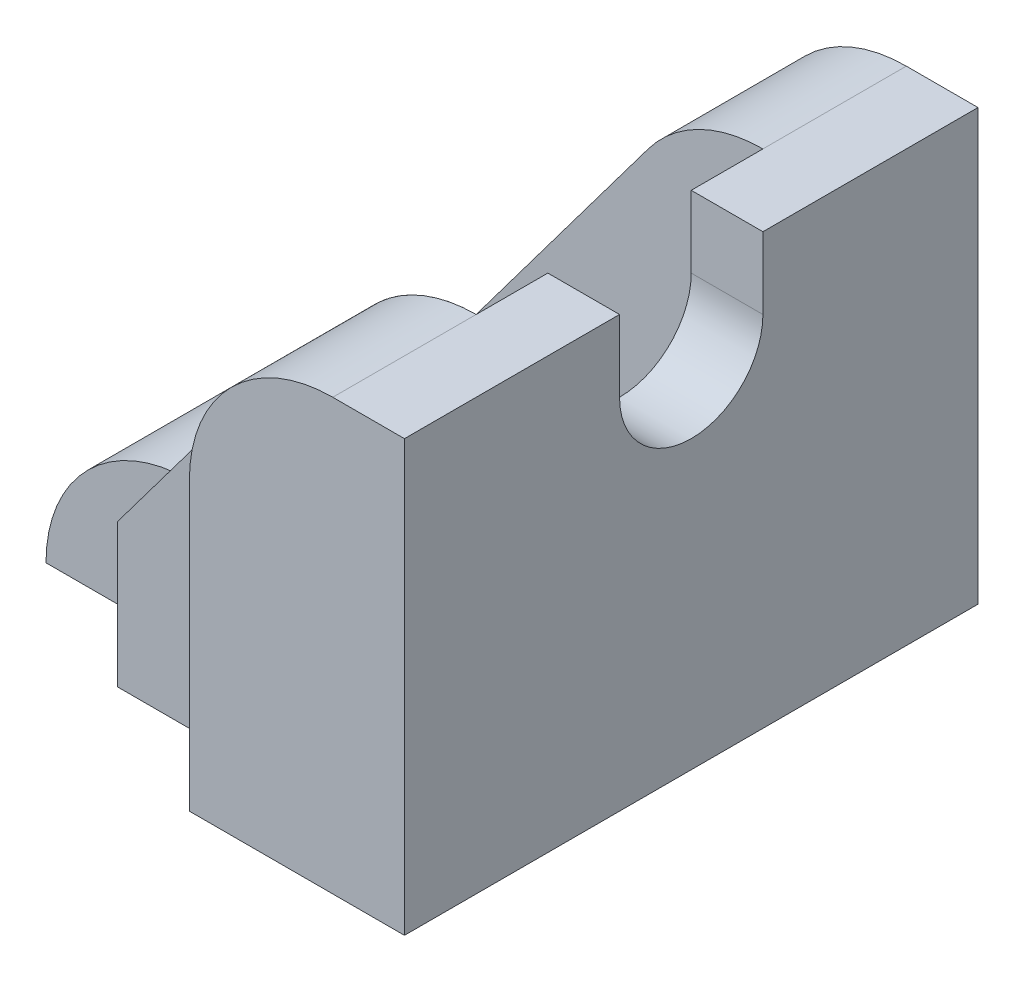
from build123d import *

# Parameters (mm, degrees)
BOSS_EXTRUDE1_DEPTH = 8
SKETCH2_W           = 4
SKETCH2_H           = 4
CUT_EXTRUDE1_DEPTH  = 4
CUT_EXTRUDE2_DEPTH  = 2
BOSS_EXTRUDE2_DEPTH = 6
CUT_EXTRUDE4_DEPTH  = 2
CUT_EXTRUDE5_DEPTH  = 3
CUT_EXTRUDE8_DEPTH  = 1
CUT_EXTRUDE9_DEPTH  = 1


with BuildPart() as part:
    # Sketch1 → Boss-Extrude1 (new body)
    with BuildSketch(Plane.XY):
        with BuildLine():
            Line((0, 0), (-3, 0))
            Line((-3, 0), (-5, 0))
            Line((-5, 0), (-5, 2))
            Line((-5, 2), (-2.6, 5.2))
            ThreePointArc((-2.6, 5.2), (-1.894427191, 5.788854382), (-1, 6))
            Line((-1, 6), (0, 6))
            Line((0, 6), (0, 0))
        make_face()
    extrude(amount=BOSS_EXTRUDE1_DEPTH)

    # Sketch2 → Cut-Extrude1 (cut)
    with BuildSketch(Plane(origin=(0, 6, 0), x_dir=(1, 0, 0), z_dir=(0, 1, 0))):
        with Locations((-3, -4)):
            Rectangle(SKETCH2_W, SKETCH2_H)
    extrude(amount=-CUT_EXTRUDE1_DEPTH, mode=Mode.SUBTRACT)

    # Sketch3 → Cut-Extrude2 (cut, through all)
    with BuildSketch(Plane.ZY.offset(1)):
        with BuildLine():
            Line((3, 6), (3, 5))
            ThreePointArc((3, 5), (4, 4), (5, 5))
            Line((5, 5), (5, 6))
            Line((5, 6), (3, 6))
        make_face()
    extrude(amount=-CUT_EXTRUDE2_DEPTH, mode=Mode.SUBTRACT)

    # Sketch5 → Boss-Extrude2 (add)
    with BuildSketch(Plane.XY.offset(8)):
        with BuildLine():
            Line((-5, 0), (-7, 0))
            ThreePointArc((-7, 0), (-6.414213562, 1.414213562), (-5, 2))
            Line((-5, 2), (-5, 0))
        make_face()
    extrude(amount=-BOSS_EXTRUDE2_DEPTH)

    # Sketch6 → Cut-Extrude4 (cut)
    with BuildSketch(Plane.XY.offset(8)):
        with BuildLine():
            Line((-5, 2), (-5, 0))
            Line((-5, 0), (-7, 0))
            ThreePointArc((-7, 0), (-6.414213562, 1.414213562), (-5, 2))
        make_face()
    extrude(amount=-CUT_EXTRUDE4_DEPTH, mode=Mode.SUBTRACT)

    # Sketch7 → Cut-Extrude5 (cut, through all)
    with BuildSketch(Plane(origin=(0, 2, 0), x_dir=(1, 0, 0), z_dir=(0, 1, 0))):
        with BuildLine():
            Line((-4, -3), (-3, -3))
            ThreePointArc((-3, -3), (-2, -4), (-3, -5))
            Line((-3, -5), (-4, -5))
            ThreePointArc((-4, -5), (-5, -4), (-4, -3))
        make_face()
    extrude(amount=-CUT_EXTRUDE5_DEPTH, mode=Mode.SUBTRACT)

    # Sketch8 → Cut-Extrude8 (cut)
    with BuildSketch(Plane.XY.offset(8)):
        with BuildLine():
            Line((-5, 0), (-3, 0))
            Line((-3, 0), (-3, 4))
            ThreePointArc((-3, 4), (-2.897366596, 4.632455532), (-2.6, 5.2))
            Line((-2.6, 5.2), (-5, 2))
            Line((-5, 2), (-5, 0))
        make_face()
    extrude(amount=-CUT_EXTRUDE8_DEPTH, mode=Mode.SUBTRACT)

    # Sketch9 → Cut-Extrude9 (cut)
    with BuildSketch(Plane(origin=(0, 0, 0), x_dir=(-1, 0, 0), z_dir=(0, 0, -1))):
        with BuildLine():
            Line((5, 0), (5, 2))
            Line((5, 2), (2.6, 5.2))
            ThreePointArc((2.6, 5.2), (2.897366596, 4.632455532), (3, 4))
            Line((3, 4), (3, 0))
            Line((3, 0), (5, 0))
        make_face()
    extrude(amount=-CUT_EXTRUDE9_DEPTH, mode=Mode.SUBTRACT)


solid = part.part
